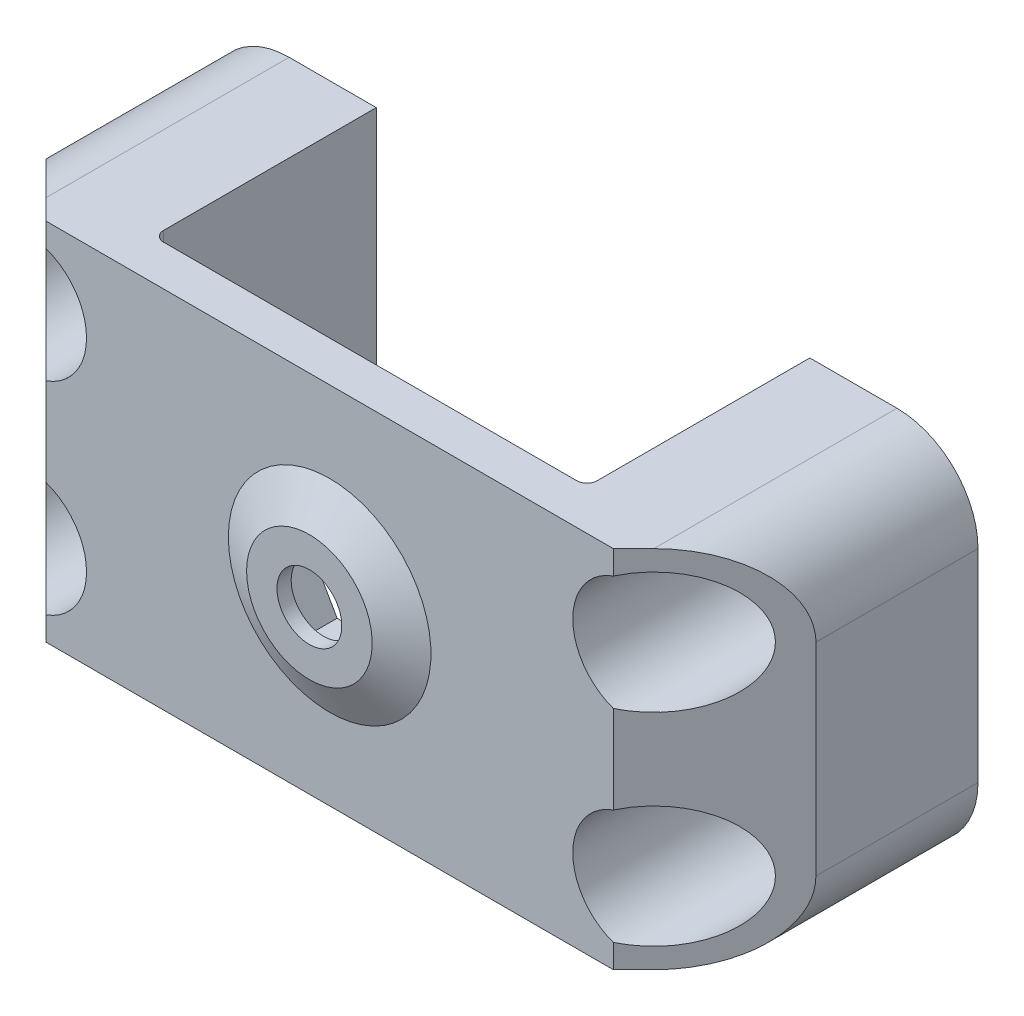
from build123d import *

# Parameters (mm, degrees)
BOSS_EXTRUDE1_DEPTH     = 9
SKETCH2_R               = 1.6
CUT_EXTRUDE1_DEPTH      = 14
SKETCH3_R               = 1.6
CUT_EXTRUDE2_DEPTH      = 3
CUT_EXTRUDE3_DEPTH      = 2.3
CUT_EXTRUDE4_DEPTH      = 10
CUT_EXTRUDE4_DEPTH_BACK = 10
FILLET2_R               = 4
FILLET5_R               = 0.5
SKETCH11_R              = 3
CUT_EXTRUDE5_DEPTH      = 11


with BuildPart() as part:
    # Sketch1 → Boss-Extrude1 (new body, symmetric)
    with BuildSketch(Plane(origin=(0, 0, 0), x_dir=(1, 0, 0), z_dir=(0, 1, 0))):
        Polygon((10.7, 13), (19, 13), (19, 0), (-19, 0), (-19, 13), (-10.7, 13), (-10.7, 2), (10.7, 2), align=None)
    extrude(amount=BOSS_EXTRUDE1_DEPTH, both=True)

    # Sketch2 → Cut-Extrude1 (cut, through all)
    with BuildSketch(Plane(origin=(0, 0, -13), x_dir=(-1, 0, 0), z_dir=(0, 0, -1))):
        with Locations((-15, 5)):
            Circle(SKETCH2_R)
        with Locations((-15, -5)):
            Circle(SKETCH2_R)
        with Locations((15, 5)):
            Circle(SKETCH2_R)
        with Locations((15, -5)):
            Circle(SKETCH2_R)
    extrude(amount=-CUT_EXTRUDE1_DEPTH, mode=Mode.SUBTRACT)

    # Sketch3 → Cut-Extrude2 (cut, through all)
    with BuildSketch(Plane(origin=(0, 0, -2), x_dir=(-1, 0, 0), z_dir=(0, 0, -1))):
        Circle(SKETCH3_R)
    extrude(amount=-CUT_EXTRUDE2_DEPTH, mode=Mode.SUBTRACT)

    # Sketch9 → Revolve1 (revolve)
    with BuildSketch(Plane(origin=(0, 0, 0), x_dir=(0, 0, -1), z_dir=(1, 0, 0))):
        Polygon((0, 1.6), (0, 5), (-1, 3.1), (-1, 1.6), align=None)
    revolve(axis=Axis((0, 0, 0), (0, 0, 1)))

    # Sketch4 → Cut-Extrude3 (cut)
    with BuildSketch(Plane(origin=(0, 0, -2), x_dir=(-1, 0, 0), z_dir=(0, 0, -1))):
        Polygon((1.602042514, 2.808343483), (-1.631075541, 2.791581257), (-3.233118056, -0.016762226), (-1.602042514, -2.808343483), (1.631075541, -2.791581257), (3.233118056, 0.016762226), align=None)
    extrude(amount=-CUT_EXTRUDE3_DEPTH, mode=Mode.SUBTRACT)

    # Sketch10 → Cut-Extrude4 (cut, two sides)
    with BuildSketch(Plane(origin=(0, 0, 0), x_dir=(1, 0, 0), z_dir=(0, 1, 0))) as cut_extrude4_sk:
        Polygon((-19, 0), (-19, 5), (-14, 0), align=None)
        Polygon((14, 0), (19, 0), (19, 5), align=None)
    extrude(amount=CUT_EXTRUDE4_DEPTH, mode=Mode.SUBTRACT)
    extrude(cut_extrude4_sk.sketch, amount=-CUT_EXTRUDE4_DEPTH_BACK, mode=Mode.SUBTRACT)

    # Fillet2
    fillet2_edges = [part.edges().sort_by_distance(p)[0] for p in [
        (-19, -9, -9),
        (-19, 9, -9),
        (19, -9, -9),
        (19, 9, -9),
    ]]
    fillet(fillet2_edges, radius=FILLET2_R)

    # Fillet5
    fillet5_edges = [part.edges().sort_by_distance(p)[0] for p in [
        (-10.7, 0, -2),
        (10.7, 0, -2),
    ]]
    fillet(fillet5_edges, radius=FILLET5_R)

    # Sketch11 → Cut-Extrude5 (cut)
    with BuildSketch(Plane.XY):
        with Locations((-15, 5)):
            Circle(SKETCH11_R)
        with Locations((-15, -5)):
            Circle(SKETCH11_R)
        with Locations((15, 5)):
            Circle(SKETCH11_R)
        with Locations((15, -5)):
            Circle(SKETCH11_R)
    extrude(amount=-CUT_EXTRUDE5_DEPTH, mode=Mode.SUBTRACT)


solid = part.part
